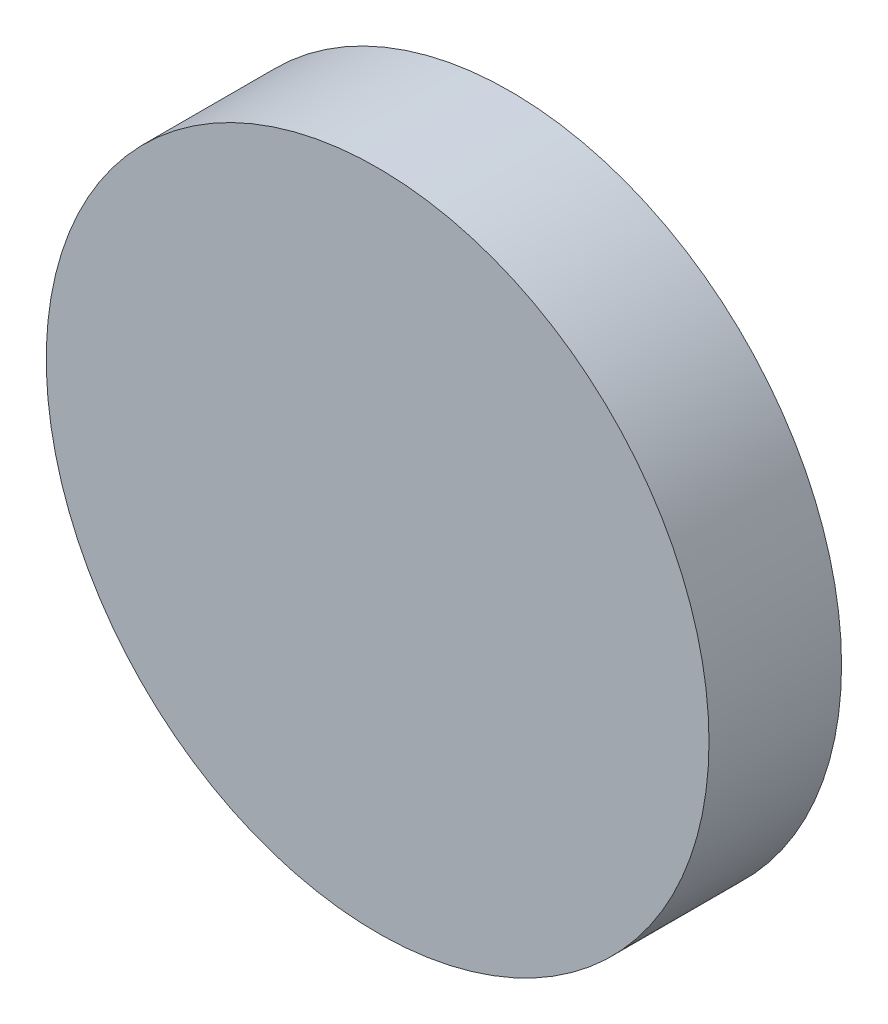
from build123d import *

# Parameters (mm, degrees)
CROQUIS1_R              = 5
SALIENTE_EXTRUIR1_DEPTH = 2
CROQUIS2_R              = 2
CORTAR_EXTRUIR1_DEPTH   = 0.5


with BuildPart() as part:
    # Croquis1 → Saliente-Extruir1 (new body)
    with BuildSketch(Plane.XY):
        Circle(CROQUIS1_R)
    extrude(amount=SALIENTE_EXTRUIR1_DEPTH)

    # Croquis2 → Cortar-Extruir1 (cut)
    with BuildSketch(Plane(origin=(0, 0, 0), x_dir=(-1, 0, 0), z_dir=(0, 0, -1))):
        Circle(CROQUIS2_R)
    extrude(amount=-CORTAR_EXTRUIR1_DEPTH, mode=Mode.SUBTRACT)


solid = part.part
